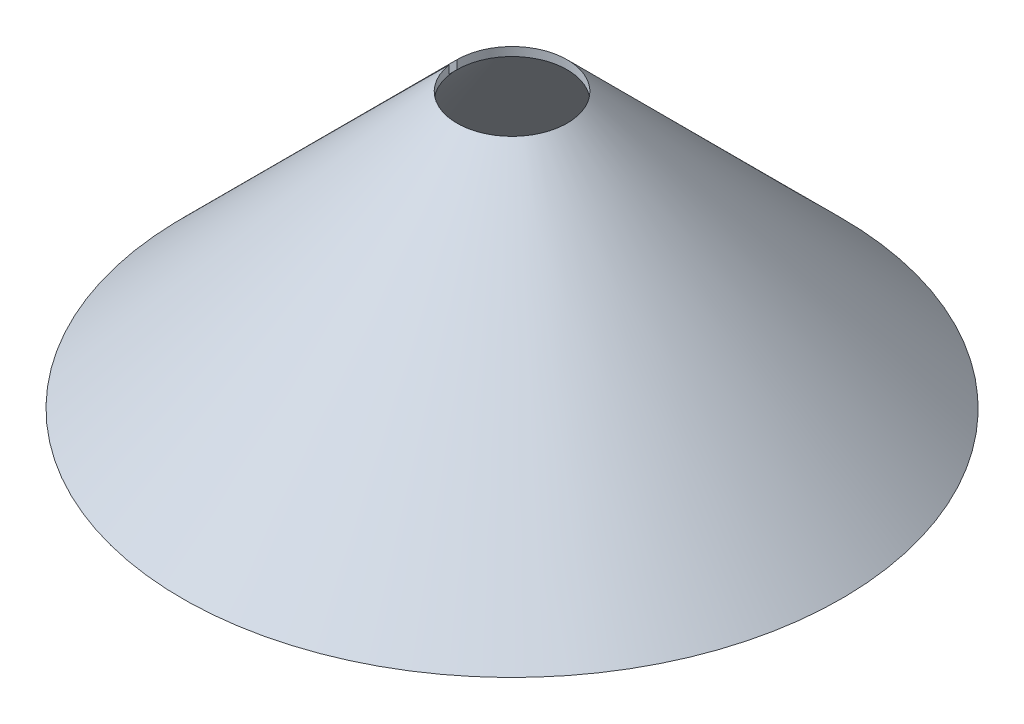
from build123d import *

# Parameters (mm, degrees)
SKETCH3_W          = 6.35
SKETCH3_H          = 17.293961796
CUT_EXTRUDE1_DEPTH = 1


with BuildPart() as part:
    # Sketch1 → Revolve1 (revolve)
    with BuildSketch(Plane.XY):
        Polygon((0, 0), (0, 38), (38, 0), align=None)
    revolve(axis=Axis((0, 0, 0), (0, 1, 0)))

    # Sketch2 → Cut-Revolve1 (revolve, cut)
    with BuildSketch(Plane.XY):
        Polygon((0, 0), (0, 37), (37, 0), align=None)
    revolve(axis=Axis((0, 0, 0), (0, 1, 0)), mode=Mode.SUBTRACT)

    # Sketch3 → Cut-Revolve2 (revolve, cut)
    with BuildSketch(Plane(origin=(0, 0, 0), x_dir=(0, 0, -1), z_dir=(1, 0, 0))):
        with Locations((3.175, 34.250129947)):
            Rectangle(SKETCH3_W, SKETCH3_H)
    revolve(axis=Axis((0, 0, 0), (0, 1, 0)), mode=Mode.SUBTRACT)

    # Sketch15 → Cut-Extrude1 (cut)
    with BuildSketch(Plane.XY):
        Polygon((-39.618894295, 0.734384701), (-37.928802574, -0.95570702), (-4.087663697, 32.885431857), (-5.777755418, 34.575523578), align=None)
    extrude(amount=CUT_EXTRUDE1_DEPTH, mode=Mode.SUBTRACT)


solid = part.part
